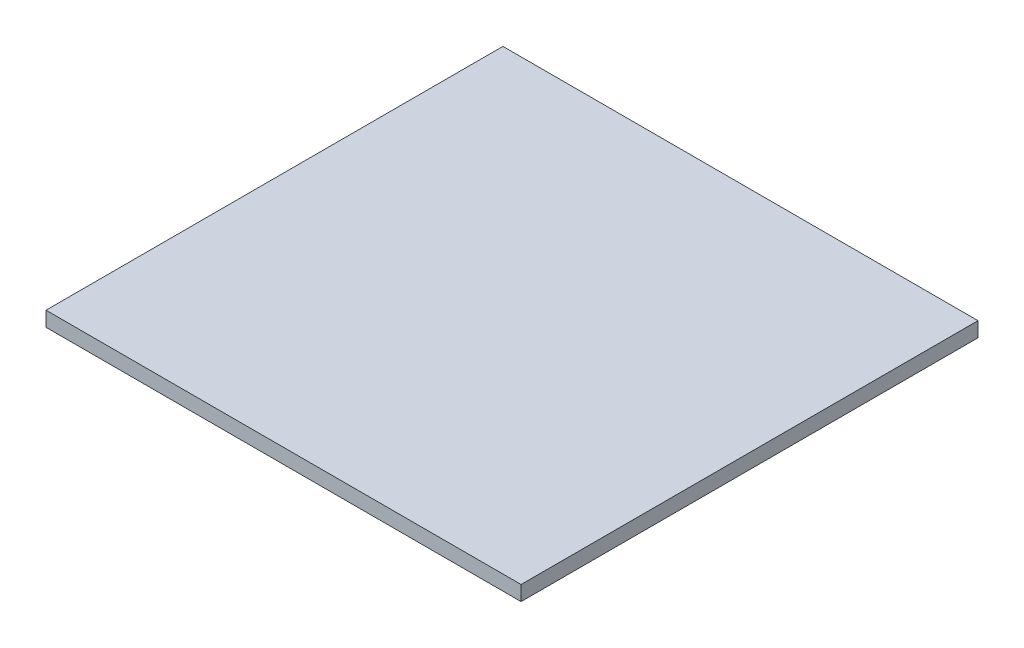
from build123d import *

# Parameters (mm, degrees)
SKETCH_1_W      = 576
SKETCH_1_H      = 554
EXTRUDE_1_DEPTH = 18


with BuildPart() as part:
    # Эскиз1 → Бобышка-Вытянуть1 (new body)
    with BuildSketch(Plane(origin=(0, 0, 0), x_dir=(1, 0, 0), z_dir=(0, 1, 0))):
        Rectangle(SKETCH_1_W, SKETCH_1_H)
    extrude(amount=EXTRUDE_1_DEPTH)


solid = part.part
